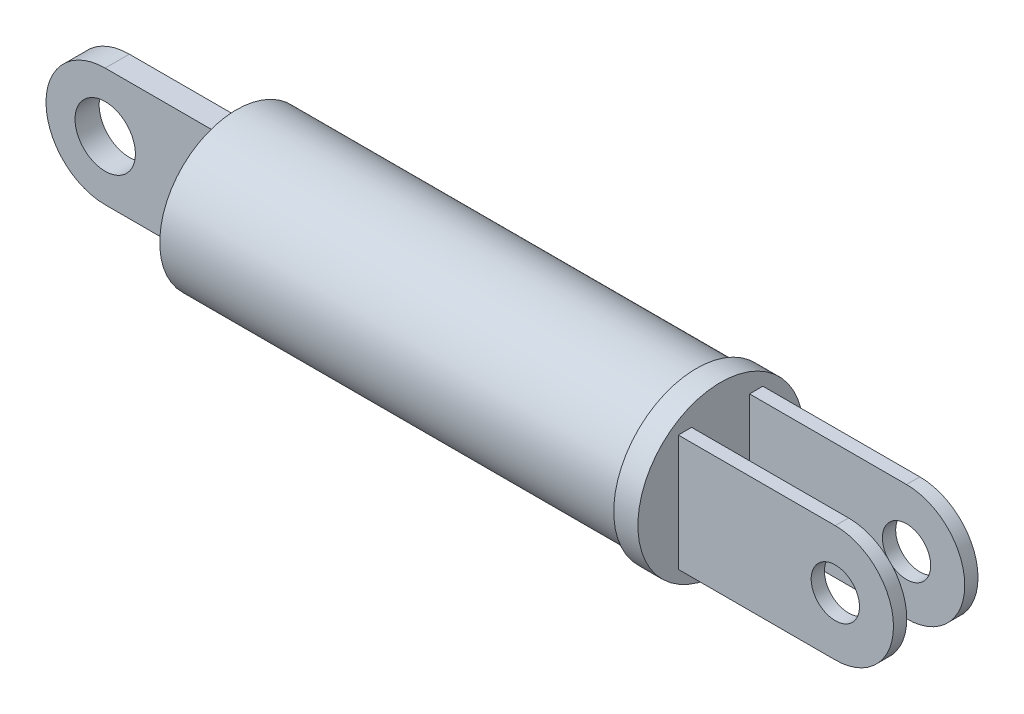
from build123d import *

# Parameters (mm, degrees)
SKETCH1_R               = 12.7
EXTRUDE1_DEPTH          = 76.2
SKETCH2_R               = 5
EXTRUDE2_DEPTH          = 2
SKETCH3_R               = 13.7
EXTRUDE3_DEPTH          = 4
SKETCH4_R               = 4
EXTRUDE4_DEPTH          = 7
SKETCH5_W               = 279.527972269
SKETCH5_H               = 9.602426348
CUT_EXTRUDE1_DEPTH      = 14.7
CUT_EXTRUDE1_DEPTH_BACK = 14.7


with BuildPart() as part:
    # Sketch1 → Extrude1 (new body)
    with BuildSketch(Plane(origin=(0, 0, 0), x_dir=(0, 0, -1), z_dir=(1, 0, 0))):
        Circle(SKETCH1_R)
    extrude(amount=EXTRUDE1_DEPTH)

    # Sketch2 → Extrude2 (add, symmetric)
    with BuildSketch(Plane.XY):
        with BuildLine():
            Line((0, 9.805687548), (-19.733094472, 9.805687548))
            ThreePointArc((-19.733094472, 9.805687548), (-29.53878202, 0), (-19.733094472, -9.805687548))
            Line((-19.733094472, -9.805687548), (0, -9.805687548))
            Line((0, -9.805687548), (0, 9.805687548))
        make_face()
        with Locations((-19.733094472, 0)):
            Circle(SKETCH2_R, mode=Mode.SUBTRACT)
    extrude(amount=EXTRUDE2_DEPTH, both=True)

    # Sketch3 → Extrude3 (add)
    with BuildSketch(Plane(origin=(76.2, 0, 0), x_dir=(0, 0, -1), z_dir=(1, 0, 0))):
        Circle(SKETCH3_R)
    extrude(amount=EXTRUDE3_DEPTH)

    # Sketch4 → Extrude4 (add, symmetric)
    with BuildSketch(Plane.XY):
        with BuildLine():
            Line((80.2, 9.635666442), (106.2, 9.635666442))
            ThreePointArc((106.2, 9.635666442), (115.835666442, 0), (106.2, -9.635666442))
            Line((106.2, -9.635666442), (80.2, -9.635666442))
            Line((80.2, -9.635666442), (80.2, 9.635666442))
        make_face()
        with Locations((106.2, 0)):
            Circle(SKETCH4_R, mode=Mode.SUBTRACT)
    extrude(amount=EXTRUDE4_DEPTH, both=True)

    # Sketch5 → Cut-Extrude1 (cut, two sides)
    with BuildSketch(Plane(origin=(0, 0, 0), x_dir=(1, 0, 0), z_dir=(0, 1, 0))) as cut_extrude1_sk:
        with Locations((219.963986135, 0)):
            Rectangle(SKETCH5_W, SKETCH5_H)
    extrude(amount=CUT_EXTRUDE1_DEPTH, mode=Mode.SUBTRACT)
    extrude(cut_extrude1_sk.sketch, amount=-CUT_EXTRUDE1_DEPTH_BACK, mode=Mode.SUBTRACT)


solid = part.part
